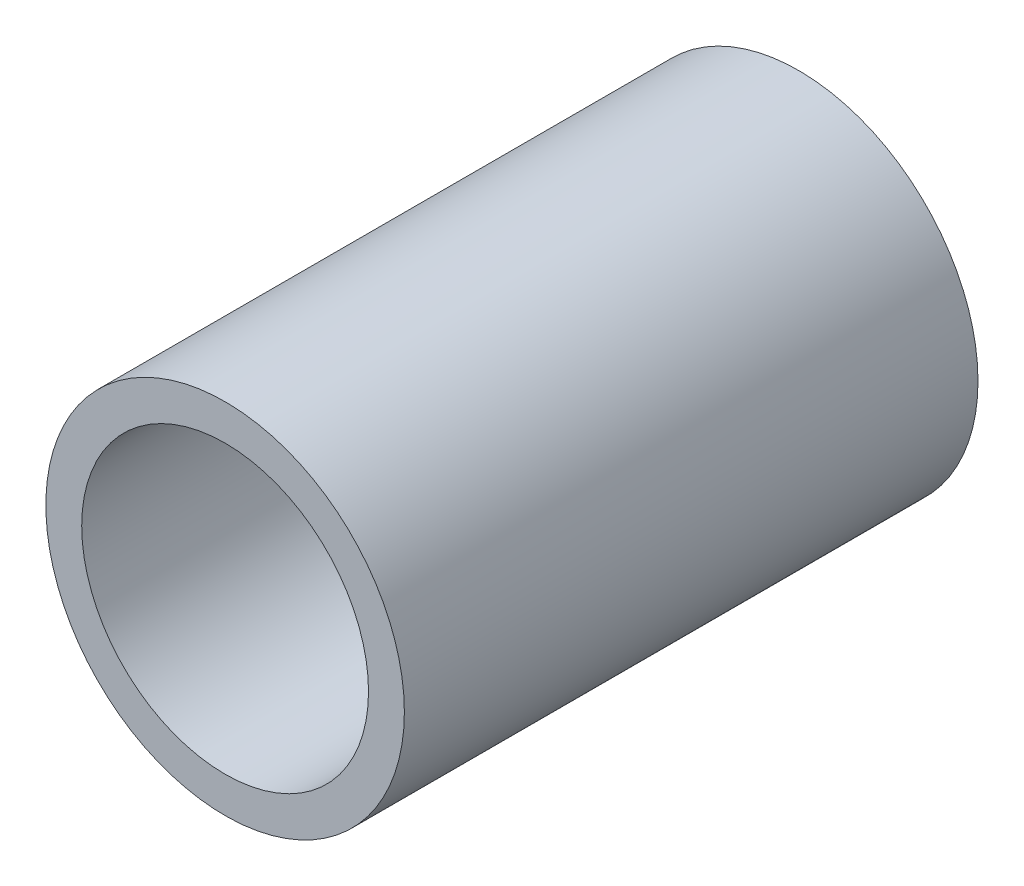
from build123d import *

# Parameters (mm, degrees)
SKETCH1_R           = 3.96875
SKETCH1_R_2         = 3.175
BOSS_EXTRUDE1_DEPTH = 12.7


with BuildPart() as part:
    # Sketch1 → Boss-Extrude1 (new body)
    with BuildSketch(Plane.XY):
        Circle(SKETCH1_R)
        Circle(SKETCH1_R_2, mode=Mode.SUBTRACT)
    extrude(amount=BOSS_EXTRUDE1_DEPTH)


solid = part.part
